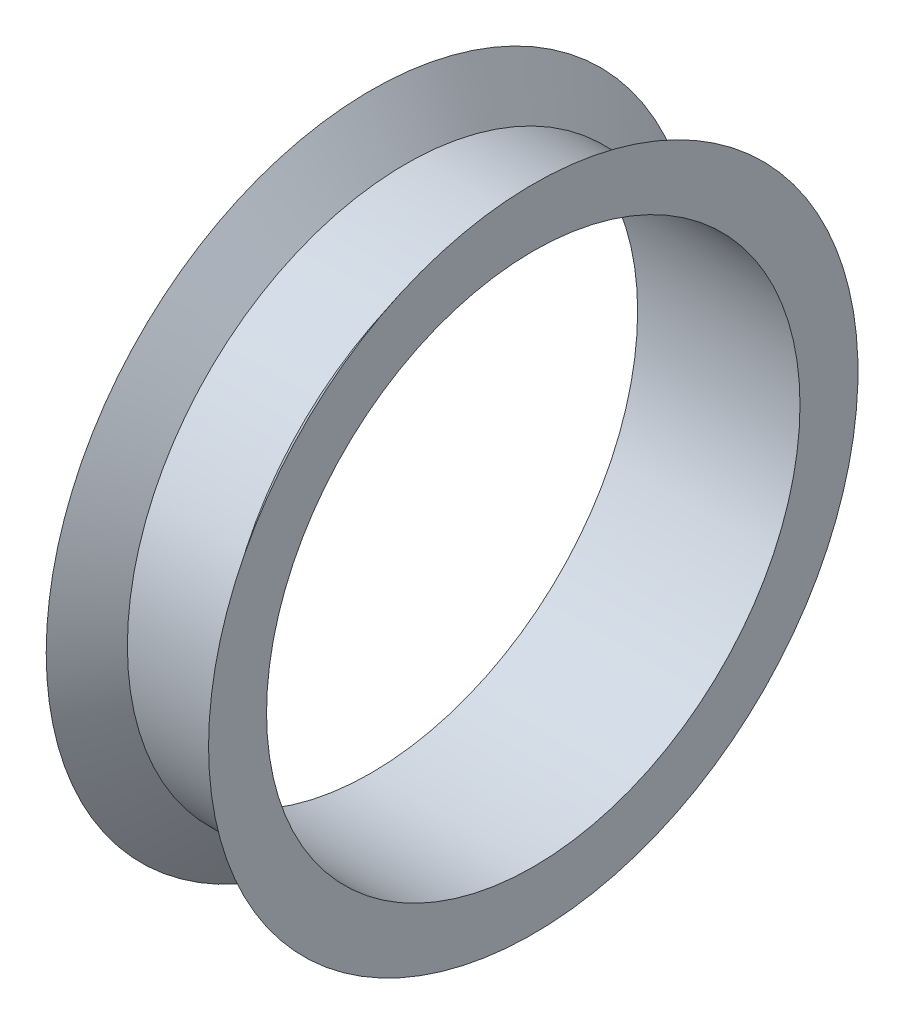
from build123d import *

# Parameters (mm, degrees)
SKETCH2_R          = 11.5
CUT_EXTRUDE1_DEPTH = 10


with BuildPart() as part:
    # Sketch1 → Revolve1 (revolve)
    with BuildSketch(Plane(origin=(0, 0, 0), x_dir=(1, 0, 0), z_dir=(0, 1, 0))):
        Polygon((-2.196930667, 5.381418675), (-2.196930667, 8.381418675), (-0.696930667, 6.381418675), (3.303069333, 6.381418675), (4.803069333, 8.381418675), (4.803069333, 5.381418675), align=None)
    revolve(axis=Axis((-2.196930667, 0, 5.618581325), (1, 0, 0)))

    # Sketch2 → Cut-Extrude1 (cut)
    with BuildSketch(Plane(origin=(4.803069333, 0, 0), x_dir=(0, 0, -1), z_dir=(1, 0, 0))):
        with Locations((-5.618581325, 0)):
            Circle(SKETCH2_R)
    extrude(amount=-CUT_EXTRUDE1_DEPTH, mode=Mode.SUBTRACT)


solid = part.part
